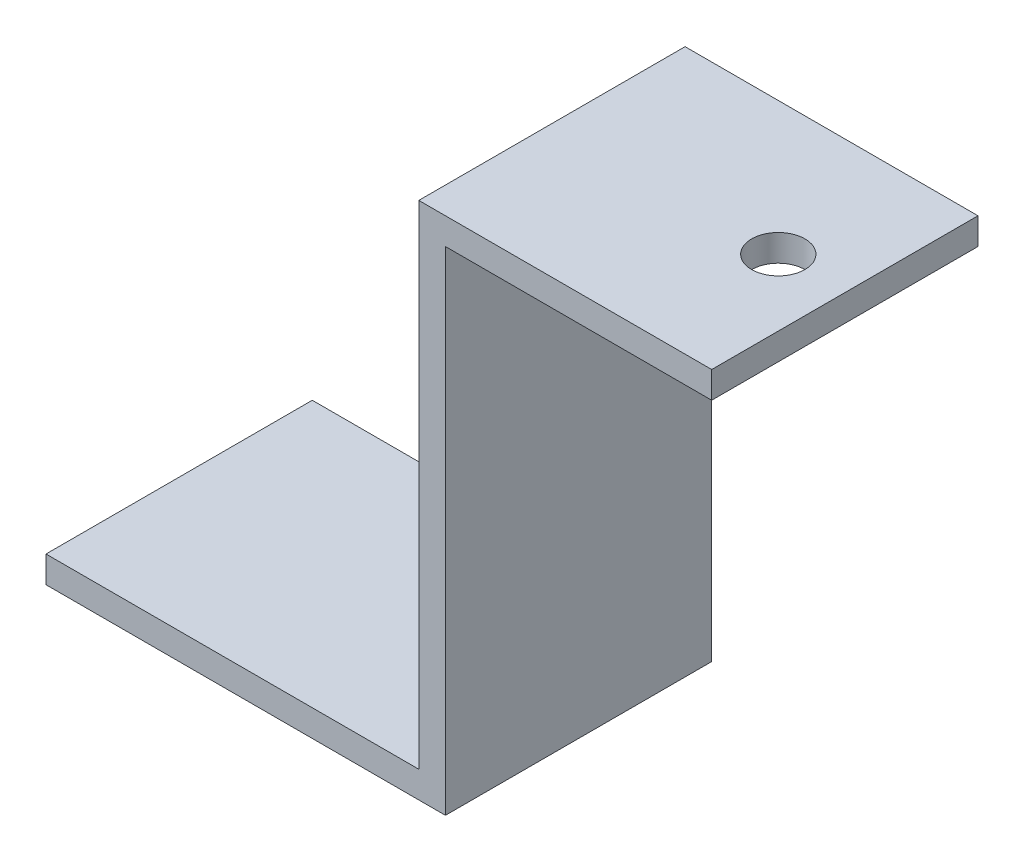
from build123d import *

# Parameters (mm, degrees)
EXTRUDE_1_DEPTH     = 20
SKETCH_2_R          = 2
CUT_EXTRUDE_1_DEPTH = 20


with BuildPart() as part:
    # 草图1 → 凸台-拉伸1 (new body)
    with BuildSketch(Plane.XY):
        Polygon((-17.175607408, 36.360314389), (-7.175607408, 36.360314389), (2.824392592, 36.360314389), (2.824392592, 34.360314389), (-17.175607408, 34.360314389), (-17.175607408, -0.639685611), (-17.175607408, -2.639685611), (-47.175607408, -2.639685611), (-47.175607408, -0.639685611), (-19.175607408, -0.639685611), (-19.175607408, 36.360314389), align=None)
    extrude(amount=EXTRUDE_1_DEPTH)

    # 草图2 → 切除-拉伸1 (cut)
    with BuildSketch(Plane(origin=(0, 36.360314389, 0), x_dir=(1, 0, 0), z_dir=(0, 1, 0))):
        with Locations((-2.175607408, -10)):
            Circle(SKETCH_2_R)
    extrude(amount=-CUT_EXTRUDE_1_DEPTH, mode=Mode.SUBTRACT)


solid = part.part
